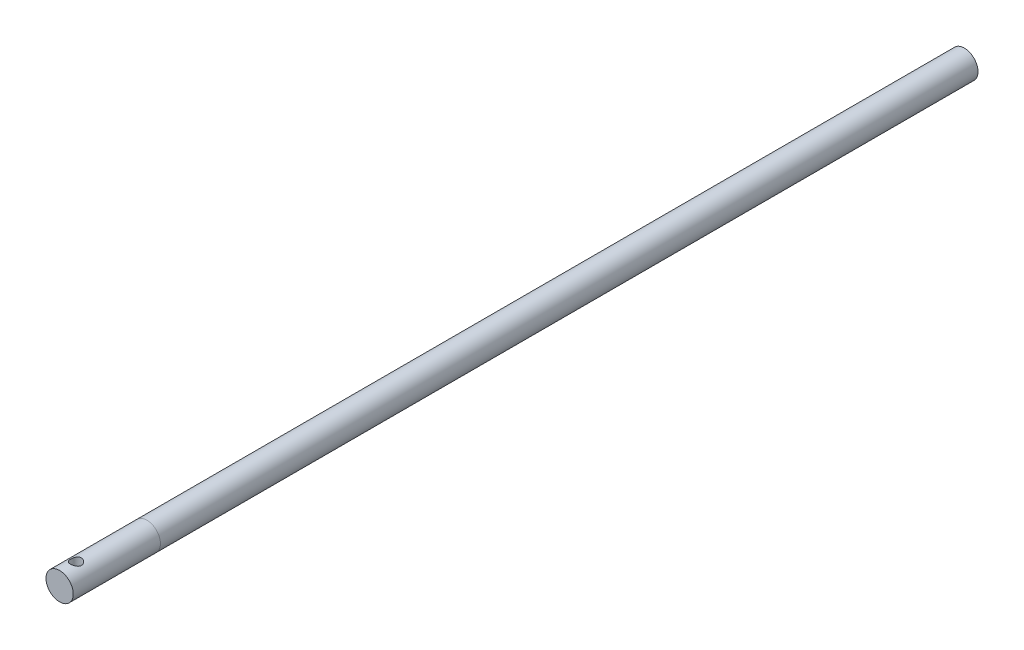
from build123d import *

# Parameters (mm, degrees)
SKETCH_1_R               = 2.5
EXTRUDE_1_DEPTH          = 150
SKETCH_2_R               = 2.5
EXTRUDE_2_DEPTH          = 16
SKETCH_3_R               = 1
CUT_EXTRUDE_1_DEPTH      = 3.5
CUT_EXTRUDE_1_DEPTH_BACK = 3.5


with BuildPart() as part:
    # 草图1 → 凸台-拉伸1 (new body)
    with BuildSketch(Plane.XY):
        Circle(SKETCH_1_R)
    extrude(amount=EXTRUDE_1_DEPTH)


with BuildPart() as body_2:
    # 草图2 → 凸台-拉伸2 (new body)
    with BuildSketch(Plane.XY.offset(150)):
        Circle(SKETCH_2_R)
    extrude(amount=EXTRUDE_2_DEPTH)

    # 草图3 → 切除-拉伸1 (cut, two sides)
    with BuildSketch(Plane(origin=(0, 0, 0), x_dir=(1, 0, 0), z_dir=(0, 1, 0))) as cut_extrude_1_sk:
        with Locations((0, -163)):
            Circle(SKETCH_3_R)
    extrude(amount=CUT_EXTRUDE_1_DEPTH, mode=Mode.SUBTRACT)
    extrude(cut_extrude_1_sk.sketch, amount=-CUT_EXTRUDE_1_DEPTH_BACK, mode=Mode.SUBTRACT)


solid = Compound([part.part, body_2.part])
